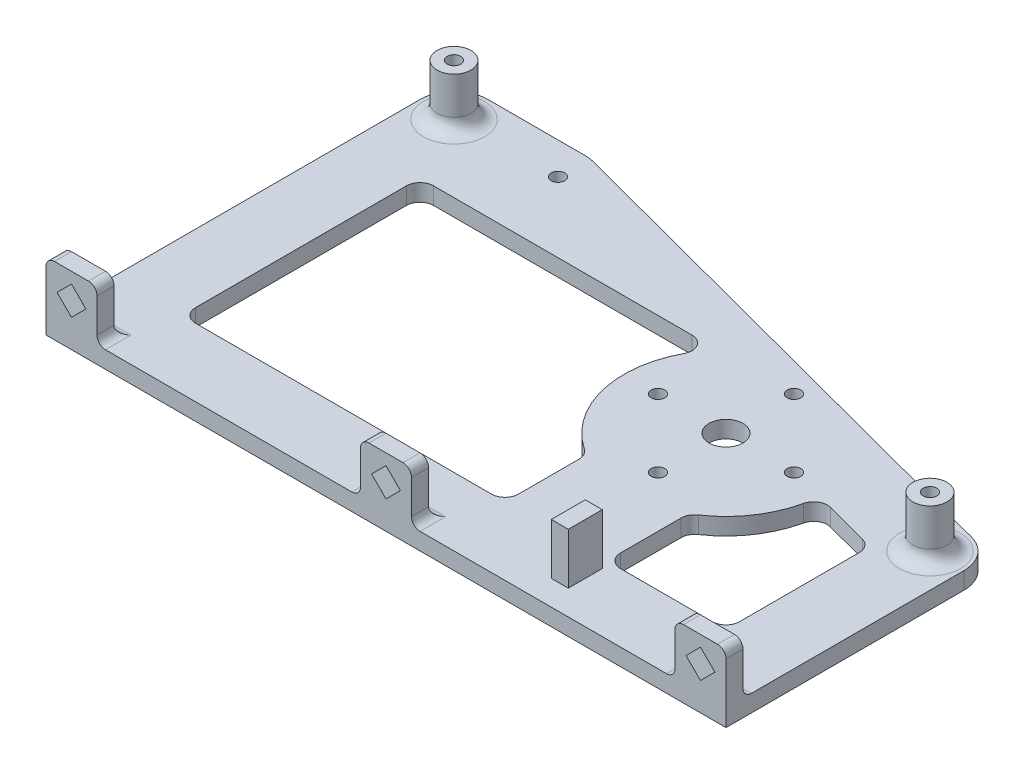
from build123d import *

# Parameters (mm, degrees)
SKETCH1_R           = 3.175
SKETCH1_R_2         = 1.27
BOSS_EXTRUDE1_DEPTH = 3.175
CUT_EXTRUDE1_DEPTH  = 3.175
FILLET1_R           = 6.35
SKETCH3_W           = 9.525
SKETCH3_H           = 9.525
BOSS_EXTRUDE2_DEPTH = 3.175
FILLET2_R           = 1.5875
SKETCH4_R           = 3.175
SKETCH4_R_2         = 1.27
BOSS_EXTRUDE3_DEPTH = 9.525
SKETCH5_W           = 3.175
SKETCH5_H           = 6.35
BOSS_EXTRUDE4_DEPTH = 9.525
FILLET4_R           = 2.54


with BuildPart() as part:
    # Sketch1 → Boss-Extrude1 (new body)
    with BuildSketch(Plane(origin=(0, 0, 0), x_dir=(1, 0, 0), z_dir=(0, 1, 0))):
        Polygon((-82.55, 31.75), (-82.55, -44.45), (44.45, -44.45), (44.45, 4.889379277), (-57.15, 31.75), align=None)
        Circle(SKETCH1_R, mode=Mode.SUBTRACT)
        with Locations((0, 12.7)):
            Circle(SKETCH1_R_2, mode=Mode.SUBTRACT)
        with Locations((12.7, 0)):
            Circle(SKETCH1_R_2, mode=Mode.SUBTRACT)
        with Locations((0, -12.7)):
            Circle(SKETCH1_R_2, mode=Mode.SUBTRACT)
        with Locations((-12.7, 0)):
            Circle(SKETCH1_R_2, mode=Mode.SUBTRACT)
        with Locations((-57.15, 25.774227063)):
            Circle(SKETCH1_R_2, mode=Mode.SUBTRACT)
        with Locations((-76.2, 25.4)):
            Circle(SKETCH1_R_2, mode=Mode.SUBTRACT)
        with Locations((38.1, 0)):
            Circle(SKETCH1_R_2, mode=Mode.SUBTRACT)
    extrude(amount=BOSS_EXTRUDE1_DEPTH)

    # Sketch2 → Cut-Extrude1 (cut)
    with BuildSketch(Plane(origin=(0, 3.175, 0), x_dir=(1, 0, 0), z_dir=(0, 1, 0))):
        with BuildLine():
            Line((-69.85, 10.16), (-69.85, -29.21))
            ThreePointArc((-69.85, -29.21), (-69.106051224, -31.006051224), (-67.31, -31.75))
            Line((-67.31, -31.75), (-12.065, -31.75))
            ThreePointArc((-12.065, -31.75), (-10.268948776, -31.006051224), (-9.525, -29.21))
            Line((-9.525, -29.21), (-9.525, -17.904297668))
            ThreePointArc((-9.525, -17.904297668), (-9.822578777, -16.711340394), (-10.645588235, -15.797909707))
            ThreePointArc((-10.645588235, -15.797909707), (-18.486020774, -4.6010364), (-16.808823529, 8.964705882))
            ThreePointArc((-16.808823529, 8.964705882), (-16.871967969, 11.466819219), (-19.05, 12.7))
            Line((-19.05, 12.7), (-67.31, 12.7))
            ThreePointArc((-67.31, 12.7), (-69.106051224, 11.956051224), (-69.85, 10.16))
        make_face()
        with BuildLine():
            Line((9.525, -17.904297668), (9.525, -29.21))
            ThreePointArc((9.525, -29.21), (10.268948776, -31.006051224), (12.065, -31.75))
            Line((12.065, -31.75), (29.21, -31.75))
            ThreePointArc((29.21, -31.75), (31.006051224, -31.006051224), (31.75, -29.21))
            Line((31.75, -29.21), (31.75, -6.845130987))
            ThreePointArc((31.75, -6.845130987), (31.222535045, -5.295517264), (29.859210479, -4.38949955))
            Line((29.859210479, -4.38949955), (21.722749497, -2.23841301))
            ThreePointArc((21.722749497, -2.23841301), (19.753320798, -2.524108077), (18.594299133, -4.141803924))
            ThreePointArc((18.594299133, -4.141803924), (15.73877231, -10.732825637), (10.645588235, -15.797909707))
            ThreePointArc((10.645588235, -15.797909707), (9.822578777, -16.711340394), (9.525, -17.904297668))
        make_face()
    extrude(amount=-CUT_EXTRUDE1_DEPTH, mode=Mode.SUBTRACT)

    # Fillet1
    fillet1_edges = [part.edges().sort_by_distance(p)[0] for p in [
        (-57.15, 1.5875, -31.75),
        (44.45, 1.5875, -4.889379277),
        (-82.55, 1.5875, -31.75),
    ]]
    fillet(fillet1_edges, radius=FILLET1_R)

    # Sketch3 → Boss-Extrude2 (add)
    with BuildSketch(Plane.XY.offset(44.45)):
        with Locations((-77.7875, 7.9375)):
            Rectangle(SKETCH3_W, SKETCH3_H)
        Polygon((-77.7875, 5.243423164), (-75.093423164, 7.9375), (-77.7875, 10.631576836), (-80.481576836, 7.9375), align=None, mode=Mode.SUBTRACT)
        with Locations((39.6875, 7.9375)):
            Rectangle(SKETCH3_W, SKETCH3_H)
        Polygon((39.6875, 5.243423164), (42.381576836, 7.9375), (39.6875, 10.631576836), (36.993423164, 7.9375), align=None, mode=Mode.SUBTRACT)
        with Locations((-19.05, 7.9375)):
            Rectangle(SKETCH3_W, SKETCH3_H)
        Polygon((-19.05, 5.243423164), (-16.355923164, 7.9375), (-19.05, 10.631576836), (-21.744076836, 7.9375), align=None, mode=Mode.SUBTRACT)
    extrude(amount=-BOSS_EXTRUDE2_DEPTH)

    # Fillet2
    fillet2_edges = [part.edges().sort_by_distance(p)[0] for p in [
        (-82.55, 12.7, 42.8625),
        (-73.025, 12.7, 42.8625),
        (-77.7875, 3.175, 41.275),
        (-73.025, 3.175, 42.8625),
        (44.45, 12.7, 42.8625),
        (39.6875, 3.175, 41.275),
        (34.925, 3.175, 42.8625),
        (34.925, 12.7, 42.8625),
        (-23.8125, 3.175, 42.8625),
        (-23.8125, 12.7, 42.8625),
        (-14.2875, 12.7, 42.8625),
        (-19.05, 3.175, 41.275),
        (-14.2875, 3.175, 42.8625),
    ]]
    fillet(fillet2_edges, radius=FILLET2_R)

    # Sketch4 → Boss-Extrude3 (add)
    with BuildSketch(Plane(origin=(0, 3.175, 0), x_dir=(1, 0, 0), z_dir=(0, 1, 0))):
        with Locations((-76.2, 25.4)):
            Circle(SKETCH4_R)
        with Locations((-76.2, 25.4)):
            Circle(SKETCH4_R_2, mode=Mode.SUBTRACT)
        with Locations((38.1, 0)):
            Circle(SKETCH4_R)
        with Locations((38.1, 0)):
            Circle(SKETCH4_R_2, mode=Mode.SUBTRACT)
    extrude(amount=BOSS_EXTRUDE3_DEPTH)

    # Sketch5 → Boss-Extrude4 (add)
    with BuildSketch(Plane(origin=(0, 3.175, 0), x_dir=(1, 0, 0), z_dir=(0, 1, 0))):
        with Locations((8.751486047, -36.616058846)):
            Rectangle(SKETCH5_W, SKETCH5_H)
    extrude(amount=BOSS_EXTRUDE4_DEPTH)

    # Fillet4
    fillet4_edges = [part.edges().sort_by_distance(p)[0] for p in [
        (-79.375, 3.175, -25.4),
        (34.925, 3.175, 0),
    ]]
    fillet(fillet4_edges, radius=FILLET4_R)


solid = part.part
